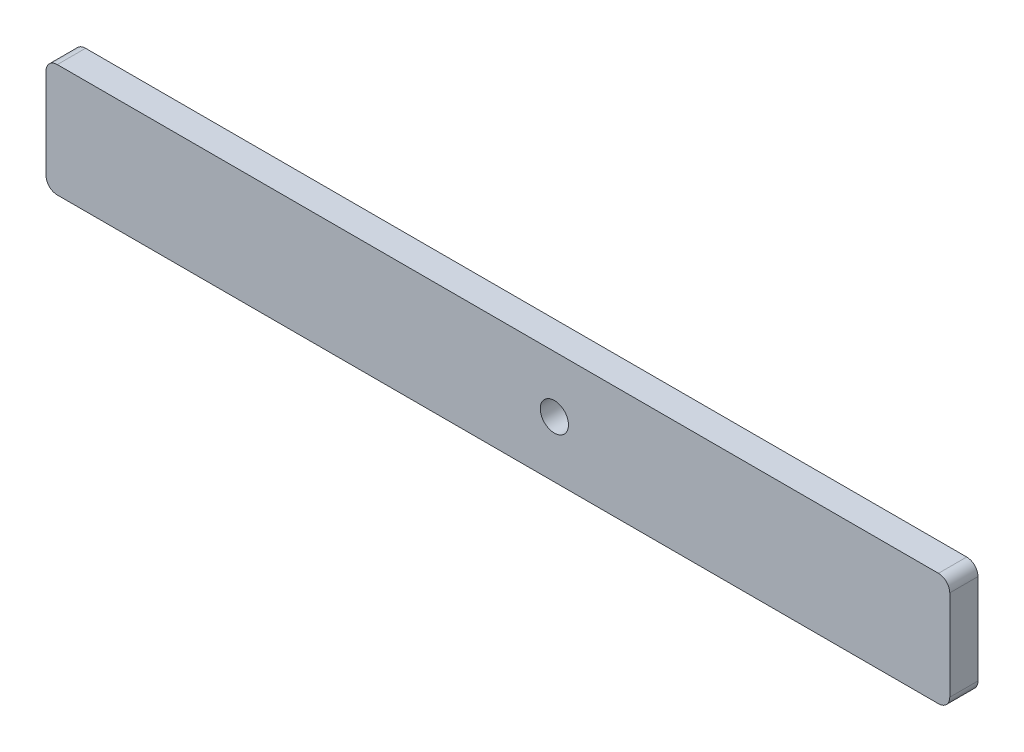
from build123d import *

# Parameters (mm, degrees)
SKETCH1_R           = 3.175
BOSS_EXTRUDE1_DEPTH = 6.35


with BuildPart() as part:
    # Sketch1 → Boss-Extrude1 (new body)
    with BuildSketch(Plane.XY):
        with BuildLine():
            Line((-99.06, 12.7), (99.06, 12.7))
            ThreePointArc((99.06, 12.7), (100.856051224, 11.956051224), (101.6, 10.16))
            Line((101.6, 10.16), (101.6, -10.16))
            ThreePointArc((101.6, -10.16), (100.856051224, -11.956051224), (99.06, -12.7))
            Line((99.06, -12.7), (-99.06, -12.7))
            ThreePointArc((-99.06, -12.7), (-100.856051224, -11.956051224), (-101.6, -10.16))
            Line((-101.6, -10.16), (-101.6, 10.16))
            ThreePointArc((-101.6, 10.16), (-100.856051224, 11.956051224), (-99.06, 12.7))
        make_face()
        with Locations((12.7, 0)):
            Circle(SKETCH1_R, mode=Mode.SUBTRACT)
    extrude(amount=BOSS_EXTRUDE1_DEPTH)


solid = part.part
